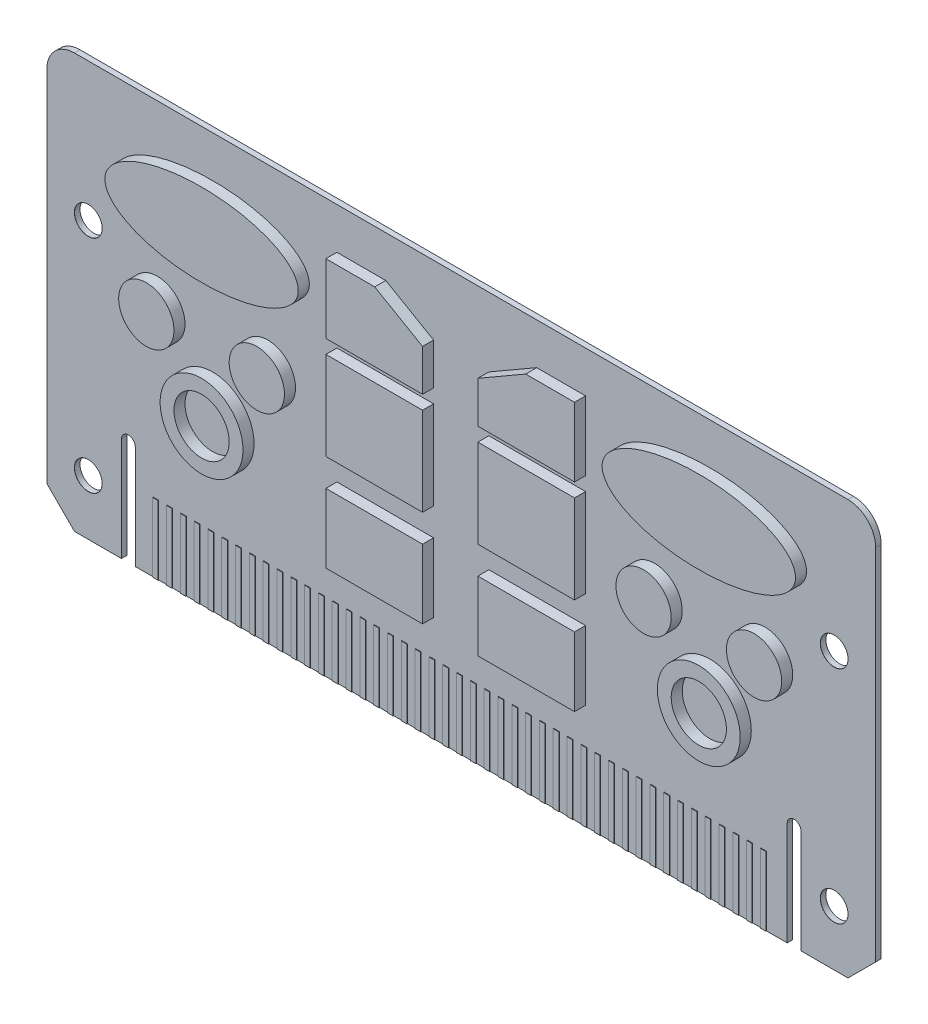
from build123d import *

# Parameters (mm, degrees)
SKETCH1_W                        = 300
SKETCH1_H                        = 150
PCB_BASE_DEPTH                   = 1
SKETCH3_R                        = 10
SKETCH3_R_2                      = 15
SKETCH3_RX                       = 35
SKETCH3_RY                       = 15
SKETCH3_W                        = 35
SKETCH3_H                        = 25
SKETCH3_H_2                      = 32
PCB_CHIPS_DEPTH                  = 4
SLOT_CUT_DEPTH                   = 10
F_10_0MM_DOWEL_HOLE1_D           = 10
F_10_0MM_DOWEL_HOLE1_DEPTH       = 10
F_10_0MM_DOWEL_HOLE1_CSINK_D     = 10.05
F_10_0MM_DOWEL_HOLE1_CSINK_ANGLE = 90
F_10_0MM_DOWEL_HOLE1_TIP         = 3.004303095
SKETCH8_W                        = 2
SKETCH8_H                        = 25
DOWN_CONTACT_DEPTH               = 0.2
CHAMFER1_SIZE                    = 10
FILLET_2_R                       = 10


with BuildPart() as part:
    # Sketch1 → PCB Base (new body, symmetric)
    with BuildSketch(Plane.XY):
        with Locations((-150, 75)):
            Rectangle(SKETCH1_W, SKETCH1_H)
    extrude(amount=PCB_BASE_DEPTH, both=True)

    # Sketch3 → PCB chips (add)
    with BuildSketch(Plane(origin=(0, 0, -1), x_dir=(-1, 0, 0), z_dir=(0, 0, -1))):
        with Locations((40, 85)):
            Circle(SKETCH3_R)
        with Locations((80, 85)):
            Circle(SKETCH3_R)
        with Locations((60, 60)):
            Circle(SKETCH3_R_2)
        with Locations((60, 60)):
            Circle(SKETCH3_R, mode=Mode.SUBTRACT)
        with Locations((240, 60)):
            Circle(SKETCH3_R_2)
        with Locations((240, 60)):
            Circle(SKETCH3_R, mode=Mode.SUBTRACT)
        with Locations((220, 85)):
            Circle(SKETCH3_R)
        with Locations((260, 85)):
            Circle(SKETCH3_R)
        with Locations(Location((60, 120), (0, 0, 0))):
            Ellipse(SKETCH3_RX, SKETCH3_RY)
        with Locations(Location((240, 120), (0, 0, 180))):
            Ellipse(SKETCH3_RX, SKETCH3_RY)
        with Locations((122.5, 50.5)):
            Rectangle(SKETCH3_W, SKETCH3_H)
        with Locations((122.5, 89)):
            Rectangle(SKETCH3_W, SKETCH3_H_2)
        Polygon((105, 110), (140, 110), (140, 125), (122.679491924, 135), (105, 135), align=None)
        Polygon((160, 125), (177.320508076, 135), (195, 135), (195, 110), (160, 110), align=None)
        with Locations((177.5, 89)):
            Rectangle(SKETCH3_W, SKETCH3_H_2)
        with Locations((177.5, 50.5)):
            Rectangle(SKETCH3_W, SKETCH3_H)
    pcb_chips = extrude(amount=PCB_CHIPS_DEPTH)

    # mirror chips: PCB chips across plane
    add(pcb_chips.mirror(Plane.XY))

    # Sketch4 → slot cut (cut)
    with BuildSketch(Plane.XY.offset(1)):
        with BuildLine():
            Line((-273, 37.5), (-273, 0))
            Line((-273, 0), (-268, 0))
            Line((-268, 0), (-268, 37.5))
            ThreePointArc((-268, 37.5), (-270.5, 40), (-273, 37.5))
        make_face()
        with BuildLine():
            Line((-32, -3.35746716), (-32, 37.5))
            ThreePointArc((-32, 37.5), (-29.5, 40), (-27, 37.5))
            Line((-27, 37.5), (-27, -3.35746716))
            ThreePointArc((-27, -3.35746716), (-29.5, -5.85746716), (-32, -3.35746716))
        make_face()
    extrude(amount=-SLOT_CUT_DEPTH, mode=Mode.SUBTRACT)

    # Ø10.0mm Dowel Hole1
    with Locations(Plane.XY.offset(1)):
        with Locations((-285, 100), (-285, 20), (-15, 20), (-15, 100)):
            CounterSinkHole(F_10_0MM_DOWEL_HOLE1_D / 2, F_10_0MM_DOWEL_HOLE1_CSINK_D / 2, depth=F_10_0MM_DOWEL_HOLE1_DEPTH, counter_sink_angle=F_10_0MM_DOWEL_HOLE1_CSINK_ANGLE)
            with Locations((0, 0, -(F_10_0MM_DOWEL_HOLE1_DEPTH + F_10_0MM_DOWEL_HOLE1_TIP / 2))):  # 118° drill point
                Cone(0, F_10_0MM_DOWEL_HOLE1_D / 2, F_10_0MM_DOWEL_HOLE1_TIP, mode=Mode.SUBTRACT)

    # Sketch8 → down contact (add)
    with BuildSketch(Plane.XY.offset(1)):
        with Locations((-260.5, 12.5)):
            Rectangle(SKETCH8_W, SKETCH8_H)
        with Locations((-255.5, 12.5)):
            Rectangle(SKETCH8_W, SKETCH8_H)
        with Locations((-250.5, 12.5)):
            Rectangle(SKETCH8_W, SKETCH8_H)
        with Locations((-245.5, 12.5)):
            Rectangle(SKETCH8_W, SKETCH8_H)
        with Locations((-240.5, 12.5)):
            Rectangle(SKETCH8_W, SKETCH8_H)
        with Locations((-235.5, 12.5)):
            Rectangle(SKETCH8_W, SKETCH8_H)
        with Locations((-230.5, 12.5)):
            Rectangle(SKETCH8_W, SKETCH8_H)
        with Locations((-225.5, 12.5)):
            Rectangle(SKETCH8_W, SKETCH8_H)
        with Locations((-220.5, 12.5)):
            Rectangle(SKETCH8_W, SKETCH8_H)
        with Locations((-215.5, 12.5)):
            Rectangle(SKETCH8_W, SKETCH8_H)
        with Locations((-210.5, 12.5)):
            Rectangle(SKETCH8_W, SKETCH8_H)
        with Locations((-205.5, 12.5)):
            Rectangle(SKETCH8_W, SKETCH8_H)
        with Locations((-200.5, 12.5)):
            Rectangle(SKETCH8_W, SKETCH8_H)
        with Locations((-195.5, 12.5)):
            Rectangle(SKETCH8_W, SKETCH8_H)
        with Locations((-190.5, 12.5)):
            Rectangle(SKETCH8_W, SKETCH8_H)
        with Locations((-185.5, 12.5)):
            Rectangle(SKETCH8_W, SKETCH8_H)
        with Locations((-180.5, 12.5)):
            Rectangle(SKETCH8_W, SKETCH8_H)
        with Locations((-175.5, 12.5)):
            Rectangle(SKETCH8_W, SKETCH8_H)
        with Locations((-170.5, 12.5)):
            Rectangle(SKETCH8_W, SKETCH8_H)
        with Locations((-165.5, 12.5)):
            Rectangle(SKETCH8_W, SKETCH8_H)
        with Locations((-160.5, 12.5)):
            Rectangle(SKETCH8_W, SKETCH8_H)
        with Locations((-155.5, 12.5)):
            Rectangle(SKETCH8_W, SKETCH8_H)
        with Locations((-150.5, 12.5)):
            Rectangle(SKETCH8_W, SKETCH8_H)
        with Locations((-145.5, 12.5)):
            Rectangle(SKETCH8_W, SKETCH8_H)
        with Locations((-140.5, 12.5)):
            Rectangle(SKETCH8_W, SKETCH8_H)
        with Locations((-135.5, 12.5)):
            Rectangle(SKETCH8_W, SKETCH8_H)
        with Locations((-130.5, 12.5)):
            Rectangle(SKETCH8_W, SKETCH8_H)
        with Locations((-125.5, 12.5)):
            Rectangle(SKETCH8_W, SKETCH8_H)
        with Locations((-120.5, 12.5)):
            Rectangle(SKETCH8_W, SKETCH8_H)
        with Locations((-115.5, 12.5)):
            Rectangle(SKETCH8_W, SKETCH8_H)
        with Locations((-110.5, 12.5)):
            Rectangle(SKETCH8_W, SKETCH8_H)
        with Locations((-105.5, 12.5)):
            Rectangle(SKETCH8_W, SKETCH8_H)
        with Locations((-100.5, 12.5)):
            Rectangle(SKETCH8_W, SKETCH8_H)
        with Locations((-95.5, 12.5)):
            Rectangle(SKETCH8_W, SKETCH8_H)
        with Locations((-90.5, 12.5)):
            Rectangle(SKETCH8_W, SKETCH8_H)
        with Locations((-85.5, 12.5)):
            Rectangle(SKETCH8_W, SKETCH8_H)
        with Locations((-80.5, 12.5)):
            Rectangle(SKETCH8_W, SKETCH8_H)
        with Locations((-75.5, 12.5)):
            Rectangle(SKETCH8_W, SKETCH8_H)
        with Locations((-70.5, 12.5)):
            Rectangle(SKETCH8_W, SKETCH8_H)
        with Locations((-65.5, 12.5)):
            Rectangle(SKETCH8_W, SKETCH8_H)
        with Locations((-60.5, 12.5)):
            Rectangle(SKETCH8_W, SKETCH8_H)
        with Locations((-55.5, 12.5)):
            Rectangle(SKETCH8_W, SKETCH8_H)
        with Locations((-50.5, 12.5)):
            Rectangle(SKETCH8_W, SKETCH8_H)
        with Locations((-45.5, 12.5)):
            Rectangle(SKETCH8_W, SKETCH8_H)
        with Locations((-40.5, 12.5)):
            Rectangle(SKETCH8_W, SKETCH8_H)
    extrude(amount=DOWN_CONTACT_DEPTH)

    # Chamfer1
    chamfer1_edges = [part.edges().sort_by_distance(p)[0] for p in [
        (0, 0, 0),
        (-300, 0, 0),
    ]]
    chamfer(chamfer1_edges, length=CHAMFER1_SIZE)

    # fillet 2
    fillet_2_edges = [part.edges().sort_by_distance(p)[0] for p in [
        (-300, 150, 0),
        (0, 150, 0),
    ]]
    fillet(fillet_2_edges, radius=FILLET_2_R)


solid = part.part
